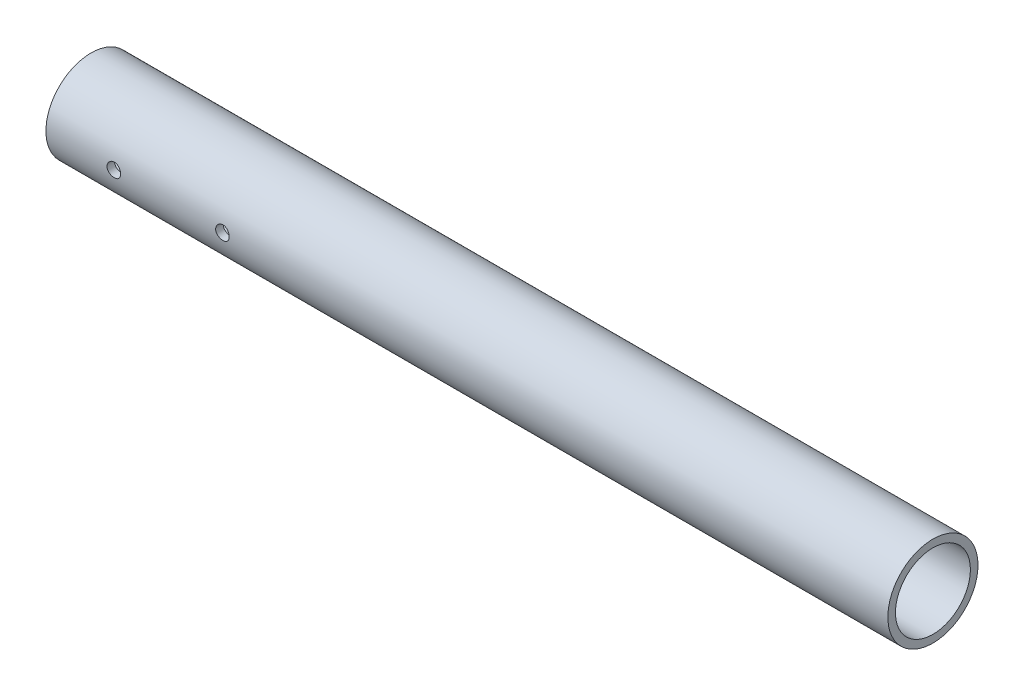
from build123d import *

# Parameters (mm, degrees)
BOSS_EXTRUDE1_DEPTH      = 196.85
BOSS_EXTRUDE1_DEPTH_BACK = 196.85
SKETCH1_R                = 21.082
SKETCH1_R_2              = 17.526
SKETCH2_R                = 3.175
CUT_EXTRUDE1_DEPTH       = 200.095012363


with BuildPart() as part:
    # Sketch1 → Boss-Extrude1 (new, two sides: drawn at the far end of the back side and taken through both)
    with BuildSketch(Plane(origin=(0, 0, 0), x_dir=(0, 0, -1), z_dir=(1, 0, 0)).offset(-BOSS_EXTRUDE1_DEPTH_BACK)):
        Circle(SKETCH1_R)
        Circle(SKETCH1_R_2, mode=Mode.SUBTRACT)
    extrude(amount=BOSS_EXTRUDE1_DEPTH + BOSS_EXTRUDE1_DEPTH_BACK)

    # Sketch2 → Cut-Extrude1 (cut, through all)
    with BuildSketch(Plane.XY):
        with Locations((-114.3, 0)):
            Circle(SKETCH2_R)
        with Locations((-165.1, 0)):
            Circle(SKETCH2_R)
    extrude(amount=CUT_EXTRUDE1_DEPTH, mode=Mode.SUBTRACT)


solid = part.part
